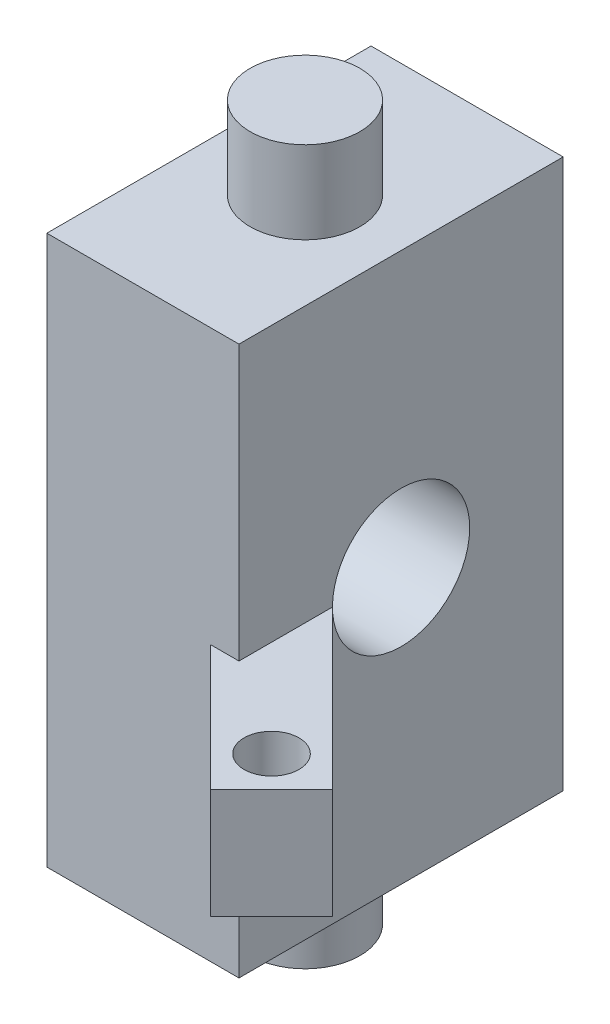
from build123d import *

# Parameters (mm, degrees)
BOSS_EXTRUDE1_DEPTH      = 16.51
BOSS_EXTRUDE1_DEPTH_BACK = 16.51
SKETCH1_3_R              = 1.27
BOSS_EXTRUDE2_DEPTH      = 5.08
SKETCH3_W                = 16.776229269
SKETCH3_H                = 3.81
CUT_EXTRUDE1_DEPTH       = 25.24914528
CUT_EXTRUDE1_DEPTH_BACK  = 25.24914528
SKETCH4_R                = 3.175


with BuildPart() as part:
    # Sketch1 → Boss-Extrude1 (new, two sides: drawn at the far end of the back side and taken through both)
    with BuildSketch(Plane(origin=(0, 0, 0), x_dir=(1, 0, 0), z_dir=(0, 1, 0)).offset(-BOSS_EXTRUDE1_DEPTH_BACK)):
        Polygon((4.445, -7.499999986), (4.445, -3.164844602), (4.445, 7.499999986), (-4.445, 7.499999986), (-4.445, -7.499999986), (3.123301134, -7.499999986), align=None)
    extrude(amount=BOSS_EXTRUDE1_DEPTH + BOSS_EXTRUDE1_DEPTH_BACK)

    # Sketch1_3 → Boss-Extrude2 (add)
    with BuildSketch(Plane(origin=(0, 0, 0), x_dir=(1, 0, 0), z_dir=(0, 1, 0))):
        Polygon((11.76066318, -10.480507782), (4.445, -3.164844602), (4.445, -7.499999986), (3.123301134, -7.499999986), (8.932236056, -13.308934907), align=None)
        with Locations((8.909608639, -10.457880365)):
            Circle(SKETCH1_3_R, mode=Mode.SUBTRACT)
    extrude(amount=-BOSS_EXTRUDE2_DEPTH)

    # Sketch3 → Cut-Revolve1 (revolve, cut)
    with BuildSketch(Plane(origin=(0, 0, 0), x_dir=(0, 0, -1), z_dir=(1, 0, 0))):
        with Locations((-10.928114634, 14.605)):
            Rectangle(SKETCH3_W, SKETCH3_H)
        with Locations((-10.928114634, -14.605)):
            Rectangle(SKETCH3_W, SKETCH3_H)
    revolve(axis=Axis((0, 0, 0), (0, 1, 0)), mode=Mode.SUBTRACT)

    # Sketch4 → Cut-Extrude1 (cut, two sides: drawn at the far end of the back side and taken through both)
    with BuildSketch(Plane(origin=(0, 0, 0), x_dir=(0, 0, -1), z_dir=(1, 0, 0)).offset(-CUT_EXTRUDE1_DEPTH_BACK)):
        Circle(SKETCH4_R)
    extrude(amount=CUT_EXTRUDE1_DEPTH + CUT_EXTRUDE1_DEPTH_BACK, mode=Mode.SUBTRACT)


solid = part.part
